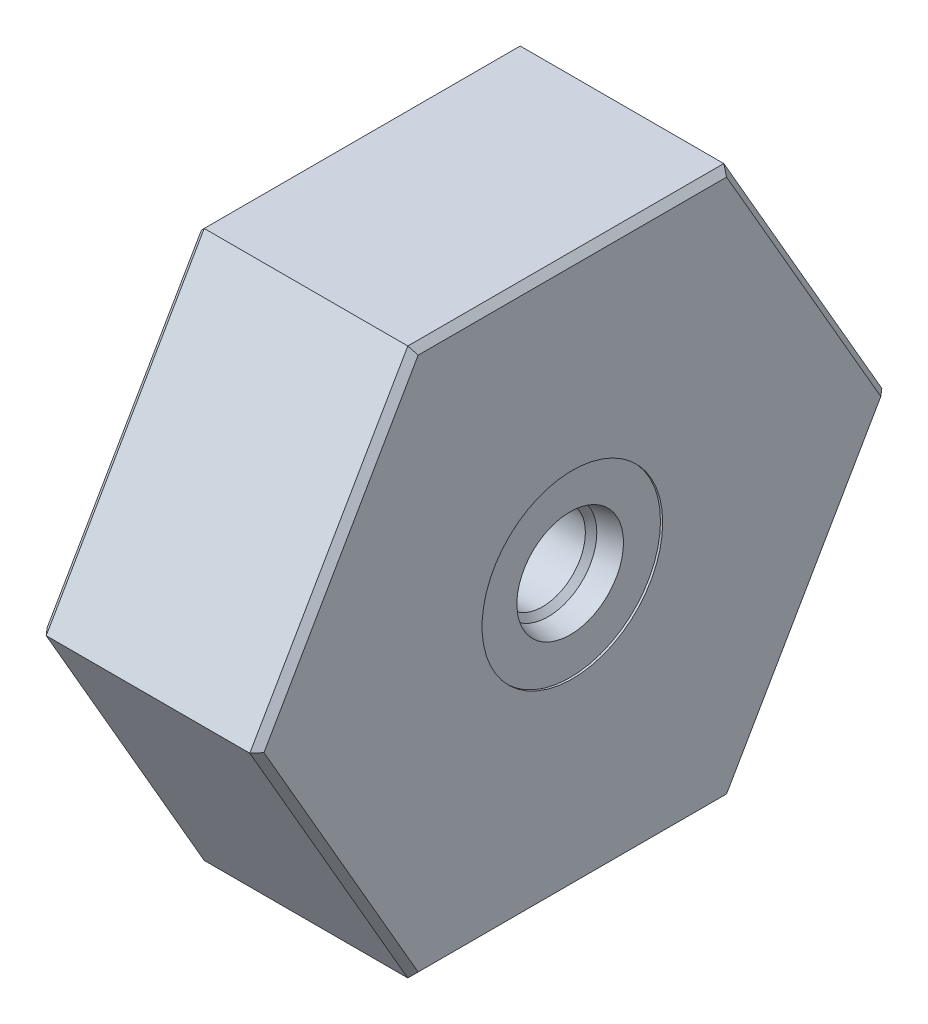
from build123d import *

# Parameters (mm, degrees)
EXTRUDE1_DEPTH = 25.146
HOLE1_D        = 16.002
HOLE1_DEPTH    = 2.286
CHAMFER1_SIZE  = 0.254
CHAMFER2_SIZE  = 0.762
CHAMFER3_SIZE  = 0.762
CHAMFER4_SIZE  = 0.762


with BuildPart() as part:
    # Sketch1 → Extrude1 (new body)
    with BuildSketch(Plane(origin=(0, 0, 0), x_dir=(0, -1, 0), z_dir=(-1, 0, 0))):
        Polygon((31.75, 18.330871047), (0, 36.661742094), (-31.75, 18.330871047), (-31.75, -18.330871047), (0, -36.661742094), (31.75, -18.330871047), align=None)
    extrude(amount=-EXTRUDE1_DEPTH)

    # Sketch2 → Cut-Revolve1 (revolve, cut)
    with BuildSketch(Plane.XY, mode=Mode.PRIVATE) as cut_revolve1_sk:
        with BuildLine():
            Line((0, 27.8003), (0, 0))
            Line((0, 0), (25.146, 0))
            Line((25.146, 0), (25.146, 10.4775))
            Line((25.146, 10.4775), (24.892, 10.4775))
            Line((24.892, 10.4775), (24.892, 6.1849))
            Line((24.892, 6.1849), (22.3393, 5.642306865))
            Line((22.3393, 5.642306865), (21.675393135, 4.9784))
            Line((21.675393135, 4.9784), (14.986, 4.9784))
            Line((14.986, 4.9784), (14.986, 27.4955))
            Line((14.986, 27.4955), (12.7, 27.4955))
            ThreePointArc((12.7, 27.4955), (12.512653369, 27.717323293), (12.234410309, 27.8003))
            Line((12.234410309, 27.8003), (0, 27.8003))
        make_face()
    revolve(cut_revolve1_sk.sketch.rotate(Axis((0, 0, 0), (1, 0, 0)), 270), axis=Axis((0, 0, 0), (1, 0, 0)), mode=Mode.SUBTRACT)  # turned: the seam where the file's is

    # Hole1
    with Locations(Plane.ZY.offset(-14.986)):
        with Locations((0, 15.24)):
            Hole(HOLE1_D / 2, depth=HOLE1_DEPTH)

    # Chamfer1
    chamfer1_edges = [part.edges().sort_by_distance(p)[0] for p in [
        (0, 0, 27.8003),
    ]]
    chamfer(chamfer1_edges, length=CHAMFER1_SIZE)

    # Chamfer2
    chamfer2_edges = [part.edges().sort_by_distance(p)[0] for p in [
        (14.986, 0, 4.9784),
    ]]
    chamfer(chamfer2_edges, length=CHAMFER2_SIZE)

    # Chamfer3
    chamfer3_edges = [part.edges().sort_by_distance(p)[0] for p in [
        (0, -15.875, -27.49630657),
        (0, 15.875, -27.49630657),
        (0, 31.75, 0),
        (0, 15.875, 27.49630657),
        (0, -15.875, 27.49630657),
        (0, -31.75, 0),
    ]]
    chamfer(chamfer3_edges, length=CHAMFER3_SIZE)

    # Chamfer4
    chamfer4_edges = [part.edges().sort_by_distance(p)[0] for p in [
        (25.146, 15.875, 27.49630657),
        (25.146, 31.75, 0),
        (25.146, 15.875, -27.49630657),
        (25.146, -15.875, -27.49630657),
        (25.146, -31.75, 0),
        (25.146, -15.875, 27.49630657),
    ]]
    chamfer(chamfer4_edges, length=CHAMFER4_SIZE)


solid = part.part
